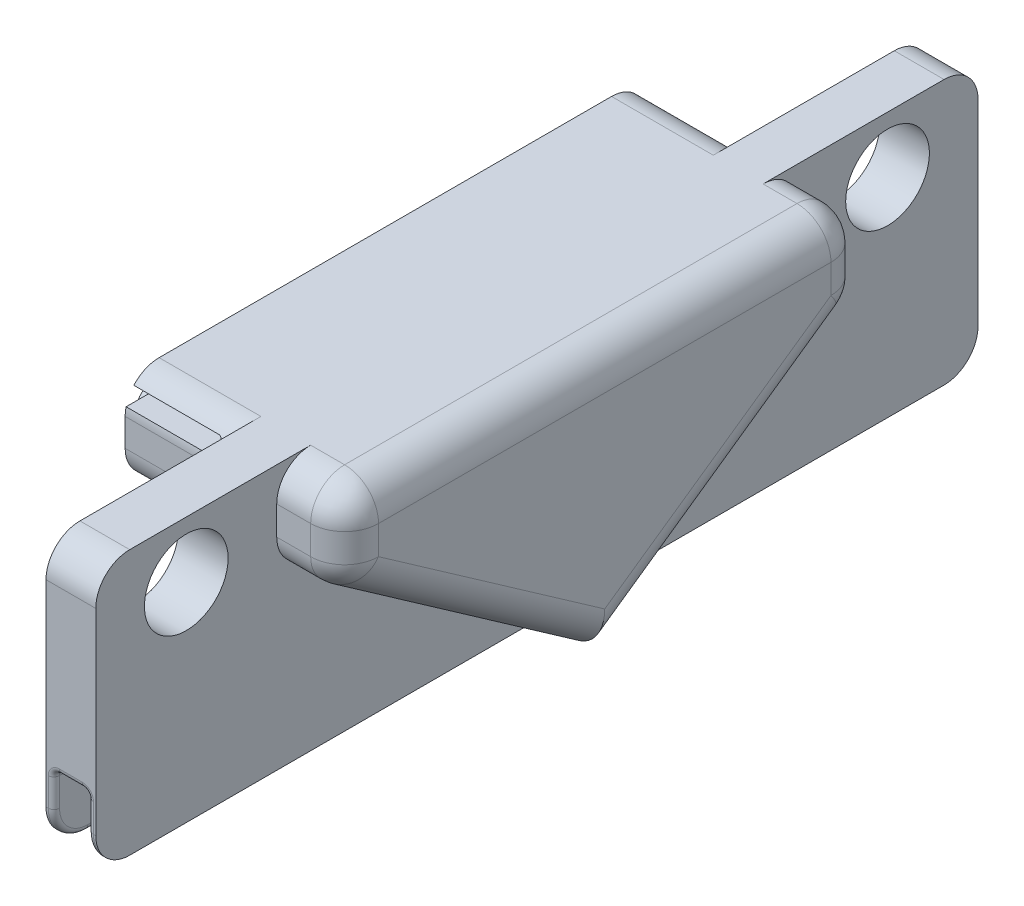
from build123d import *

# Parameters (mm, degrees)
BOSS_EXTRUDE1_DEPTH     = 11.7
SKETCH7_W               = 11.5
SKETCH7_H               = 0.65
CUT_EXTRUDE2_DEPTH      = 4
SKETCH7_4_R             = 1.6
BOSS_EXTRUDE2_DEPTH     = 1.4
CUT_EXTRUDE3_DEPTH      = 4.5
SKETCH7_6_R             = 1.85
CUT_EXTRUDE4_DEPTH      = 2.4
CUT_EXTRUDE4_DEPTH_BACK = 10.7
CUT_EXTRUDE5_DEPTH      = 3
SKETCH12_W              = 1.5
SKETCH12_H              = 21.000689182
CUT_EXTRUDE6_DEPTH      = 3
SKETCH14_W              = 2.2
SKETCH14_H              = 4
BOSS_EXTRUDE3_DEPTH     = 1
FILLET3_R               = 1.5
FILLET4_R               = 0.25


with BuildPart() as part:
    # Sketch1 → Boss-Extrude1 (new body)
    with BuildSketch(Plane(origin=(0, 0, 0), x_dir=(1, 0, 0), z_dir=(0, 1, 0))):
        Polygon((-28.77817965, 14.04419618), (-24.27817965, 14.04419618), (-24.27817965, 22.04419618), (-22.07817965, 22.04419618), (-22.07817965, 14.04419618), (-19.07817965, 14.04419618), (-19.07817965, 2.54419618), (-28.77817965, 2.54419618), align=None)
    extrude(amount=BOSS_EXTRUDE1_DEPTH)

    # Sketch7 → Cut-Extrude2 (cut)
    with BuildSketch(Plane.ZY.offset(28.77817965)):
        with Locations((-8.29419618, 10.875)):
            Rectangle(SKETCH7_W, SKETCH7_H)
    extrude(amount=-CUT_EXTRUDE2_DEPTH, mode=Mode.SUBTRACT)

    # Sketch7_4 → Boss-Extrude2 (add)
    with BuildSketch(Plane.ZY.offset(28.77817965)):
        with Locations((-10.79419618, 8.2)):
            Circle(SKETCH7_4_R)
    extrude(amount=BOSS_EXTRUDE2_DEPTH)

    # Sketch7_5 → Cut-Extrude3 (cut)
    with BuildSketch(Plane.ZY.offset(28.77817965)):
        Polygon((-2.54419618, 0.097302003), (-14.04419618, 8.2), (-14.04419618, 0), (-2.54419618, 0), align=None)
    extrude(amount=-CUT_EXTRUDE3_DEPTH, mode=Mode.SUBTRACT)

    # Sketch7_6 → Cut-Extrude4 (cut, two sides)
    with BuildSketch(Plane.ZY.offset(28.77817965)) as cut_extrude4_sk:
        with Locations((-18.04419618, 9.2)):
            Circle(SKETCH7_6_R)
    extrude(amount=CUT_EXTRUDE4_DEPTH, mode=Mode.SUBTRACT)
    extrude(cut_extrude4_sk.sketch, amount=-CUT_EXTRUDE4_DEPTH_BACK, mode=Mode.SUBTRACT)

    # Sketch10 → Cut-Extrude5 (cut)
    with BuildSketch(Plane(origin=(-22.07817965, 0, 0), x_dir=(0, 0, -1), z_dir=(1, 0, 0))):
        Polygon((15.54419618, 9.2), (15.54419618, 0), (2.54419618, 0), (2.54419618, 0.097302003), align=None)
    extrude(amount=CUT_EXTRUDE5_DEPTH, mode=Mode.SUBTRACT)

    # Sketch12 → Cut-Extrude6 (cut)
    with BuildSketch(Plane.XZ):
        with Locations((-23.17817965, -11.543851589)):
            Rectangle(SKETCH12_W, SKETCH12_H)
    extrude(amount=-CUT_EXTRUDE6_DEPTH, mode=Mode.SUBTRACT)

    # Sketch14 → Boss-Extrude3 (add)
    with BuildSketch(Plane(origin=(0, 0, 0), x_dir=(-1, 0, 0), z_dir=(0, -1, 0))):
        with Locations((23.17817965, 4.54419618)):
            Rectangle(SKETCH14_W, SKETCH14_H)
    extrude(amount=-BOSS_EXTRUDE3_DEPTH)

    # Fillet3
    fillet3_edges = [part.edges().sort_by_distance(p)[0] for p in [
        (-26.52817965, 8.2, -14.04419618),
        (-20.57817965, 8.149688693, -14.04419618),
        (-26.52817965, 11.7, -14.04419618),
        (-20.57817965, 11.7, -14.04419618),
        (-19.07817965, 4.123495348, -8.29419618),
        (-19.07817965, 9.924844346, -14.04419618),
        (-19.07817965, 11.7, -8.29419618),
        (-23.17817965, 11.7, -22.04419618),
        (-24.10317965, 0, -22.04419618),
        (-22.25317965, 0, -22.04419618),
    ]]
    fillet(fillet3_edges, radius=FILLET3_R)

    # Mirror3: part across plane


with BuildPart() as part_1:
    add(part.part)
    add(part.part.mirror(Plane(origin=(-19.07817965, 11.7, -2.54419618), x_dir=(1, 0, 0), z_dir=(0, 0, -1))))

    # Fillet4
    fillet4_edges = [part_1.edges().sort_by_distance(p)[0] for p in [
        (-22.42817965, 3, -2.54419618),
        (-23.92817965, 3, -2.54419618),
        (-23.92817965, 2.25, -22.04419618),
        (-23.17817965, 3, -22.04419618),
        (-22.42817965, 2.25, -22.04419618),
        (-23.92817965, 0, -13.54419618),
        (-23.92817965, 1, -2.54419618),
        (-23.92817965, 0.5, -6.54419618),
        (-23.17817965, 1, -6.54419618),
        (-22.42817965, 0.5, -6.54419618),
        (-22.42817965, 1, -2.54419618),
        (-23.17817965, 0, -6.54419618),
        (-22.42817965, 0, -13.54419618),
        (-23.92817965, 0.439339828, -21.604856352),
        (-22.42817965, 0.439339828, -21.604856352),
        (-24.77817965, 10.55, -2.54419618),
        (-23.17817965, 3, 16.95580382),
        (-22.42817965, 2.25, 16.95580382),
        (-22.42817965, 0, 8.45580382),
        (-23.92817965, 0, 8.45580382),
        (-23.92817965, 2.25, 16.95580382),
        (-22.42817965, 0.5, 1.45580382),
        (-23.92817965, 0.5, 1.45580382),
        (-23.17817965, 0, 1.45580382),
        (-23.17817965, 1, 1.45580382),
        (-23.92817965, 0.439339828, 16.516463992),
        (-22.42817965, 0.439339828, 16.516463992),
        (-24.77817965, 11.2, -2.54419618),
    ]]
    fillet(fillet4_edges, radius=FILLET4_R)


solid = part_1.part
